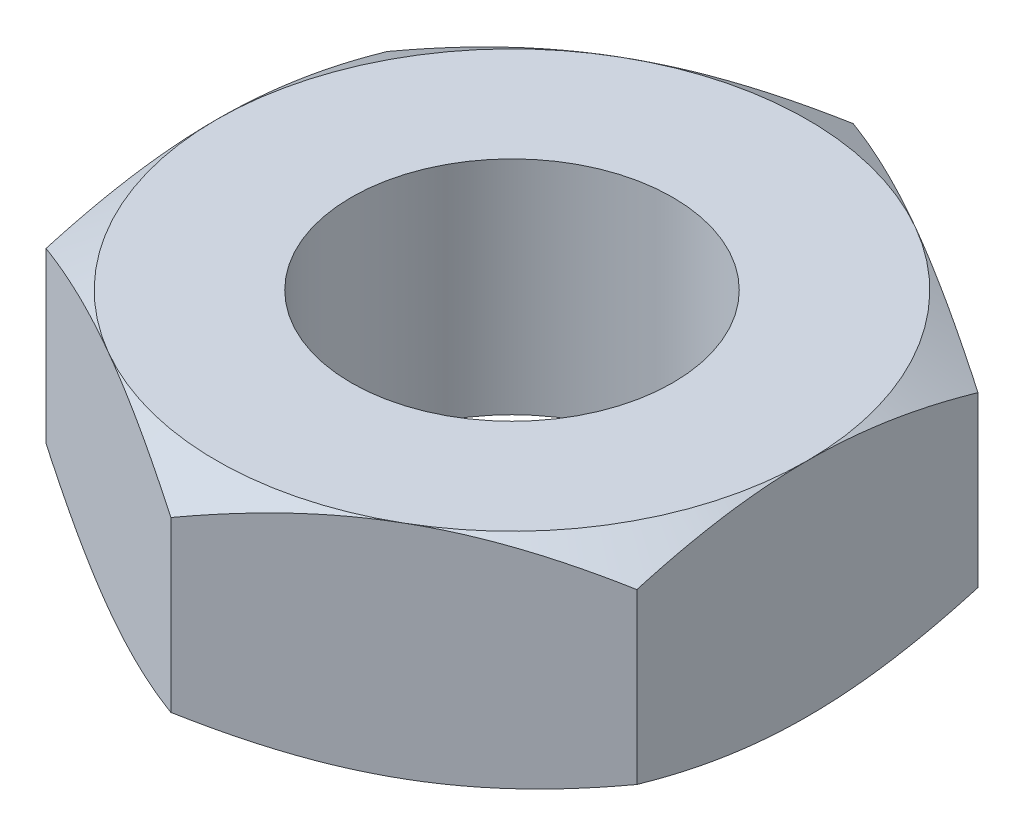
from build123d import *

# Parameters (mm, degrees)
BOSS_EXTRUDE1_DEPTH      = 2.38125
F_5_16_24_TAPPED_HOLE1_D = 6.9088
SKETCH5_OUTSIDE_W        = 38.658
SKETCH5_OUTSIDE_H        = 40.622
SKETCH5_OUTSIDE_R        = 6.35
CUT_EXTRUDE2_DEPTH       = 5.7625
CUT_EXTRUDE2_TAPER       = 60


with BuildPart() as part:
    # Sketch1 → Boss-Extrude1 (new body, symmetric)
    with BuildSketch(Plane(origin=(0, 0, 0), x_dir=(1, 0, 0), z_dir=(0, 1, 0))):
        Polygon((-6.35, 3.666174209), (-6.35, -3.666174209), (0, -7.332348419), (6.35, -3.666174209), (6.35, 3.666174209), (0, 7.332348419), align=None)
    extrude(amount=BOSS_EXTRUDE1_DEPTH, both=True)

    # 5/16-24 Tapped Hole1 (through all)
    with Locations(Plane(origin=(0, 2.38125, 0), x_dir=(1, 0, 0), z_dir=(0, 1, 0))):
        with Locations((0, 0)):
            Hole(F_5_16_24_TAPPED_HOLE1_D / 2)

    # Sketch5 outside → Cut-Extrude2 (cut, through all)
    with BuildSketch(Plane(origin=(0, 2.38125, 0), x_dir=(1, 0, 0), z_dir=(0, 1, 0))):
        Rectangle(SKETCH5_OUTSIDE_W, SKETCH5_OUTSIDE_H)
        Circle(SKETCH5_OUTSIDE_R, mode=Mode.SUBTRACT)
    cut_extrude2 = extrude(amount=-CUT_EXTRUDE2_DEPTH, taper=CUT_EXTRUDE2_TAPER, mode=Mode.SUBTRACT)

    # Mirror1: Cut-Extrude2 across plane
    add(cut_extrude2.mirror(Plane.ZX), mode=Mode.SUBTRACT)


solid = part.part
